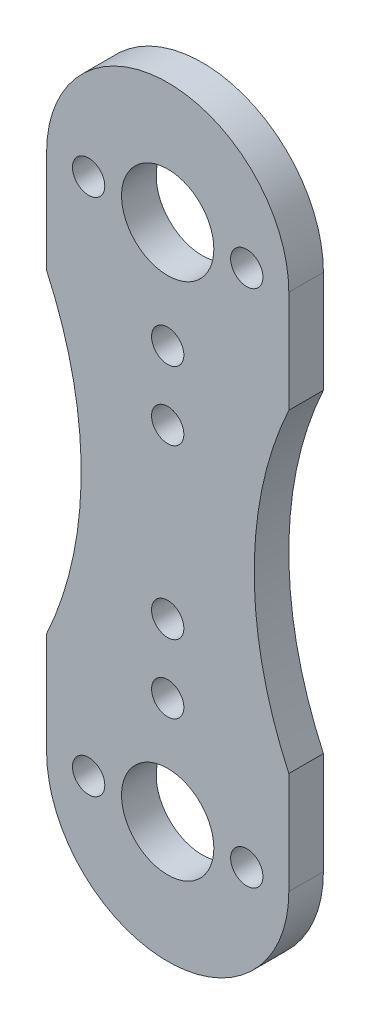
from build123d import *

# Parameters (mm, degrees)
SKETCH_1_R      = 4
SKETCH_1_R_2    = 1.4
EXTRUDE_1_DEPTH = 3


with BuildPart() as part:
    # 草图1 → 凸台-拉伸1 (new body)
    with BuildSketch(Plane.XY):
        with BuildLine():
            Line((10.5, -13.638181697), (10.5, -22.5))
            ThreePointArc((10.5, -22.5), (0, -33), (-10.5, -22.5))
            Line((-10.5, -22.5), (-10.5, -13.638181697))
            ThreePointArc((-10.5, -13.638181697), (-7.5, 0), (-10.5, 13.638181697))
            Line((-10.5, 13.638181697), (-10.5, 22.5))
            ThreePointArc((-10.5, 22.5), (0, 33), (10.5, 22.5))
            Line((10.5, 22.5), (10.5, 13.638181697))
            ThreePointArc((10.5, 13.638181697), (7.5, 0), (10.5, -13.638181697))
        make_face()
        with Locations((0, 22.5)):
            Circle(SKETCH_1_R, mode=Mode.SUBTRACT)
        with Locations((0, -22.5)):
            Circle(SKETCH_1_R, mode=Mode.SUBTRACT)
        with Locations((0, 13.23)):
            Circle(SKETCH_1_R_2, mode=Mode.SUBTRACT)
        with Locations((6.855, 22.5)):
            Circle(SKETCH_1_R_2, mode=Mode.SUBTRACT)
        with Locations((-6.855, 22.5)):
            Circle(SKETCH_1_R_2, mode=Mode.SUBTRACT)
        with Locations((0, -7.28)):
            Circle(SKETCH_1_R_2, mode=Mode.SUBTRACT)
        with Locations((0, -13.23)):
            Circle(SKETCH_1_R_2, mode=Mode.SUBTRACT)
        with Locations((-6.855, -22.5)):
            Circle(SKETCH_1_R_2, mode=Mode.SUBTRACT)
        with Locations((0, 7.28)):
            Circle(SKETCH_1_R_2, mode=Mode.SUBTRACT)
        with Locations((6.855, -22.5)):
            Circle(SKETCH_1_R_2, mode=Mode.SUBTRACT)
    extrude(amount=EXTRUDE_1_DEPTH)


solid = part.part
